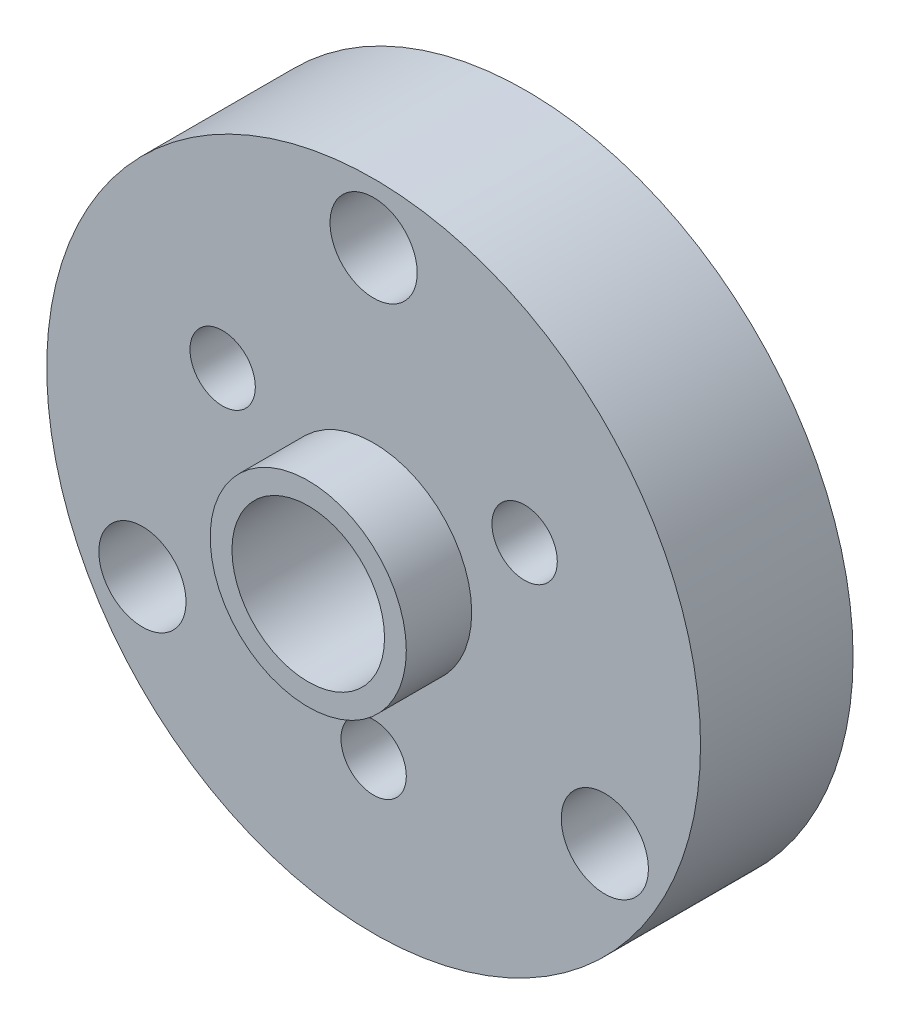
from build123d import *

# Parameters (mm, degrees)
ESQUISSE1_R      = 15
ESQUISSE1_R_2    = 3.5
ESQUISSE1_R_3    = 2
ESQUISSE1_R_4    = 1.5
EXTRUSION1_DEPTH = 7
ESQUISSE2_R      = 4.5
ESQUISSE2_R_2    = 3.5
EXTRUSION2_DEPTH = 3
ESQUISSE3_R      = 6
EXTRUSION3_DEPTH = 4
ESQUISSE4_R      = 5
ESQUISSE4_R_2    = 3.5
EXTRUSION4_DEPTH = 0.5


with BuildPart() as part:
    # Esquisse1 → Extrusion1 (new body)
    with BuildSketch(Plane.XY):
        Circle(ESQUISSE1_R)
        Circle(ESQUISSE1_R_2, mode=Mode.SUBTRACT)
        with Locations((10.608811196, -6.125)):
            Circle(ESQUISSE1_R_3, mode=Mode.SUBTRACT)
        with Locations((0, 12.25)):
            Circle(ESQUISSE1_R_3, mode=Mode.SUBTRACT)
        with Locations((-10.608811196, -6.125)):
            Circle(ESQUISSE1_R_3, mode=Mode.SUBTRACT)
        with Locations((-6.92820323, 4)):
            Circle(ESQUISSE1_R_4, mode=Mode.SUBTRACT)
        with Locations((6.92820323, 4)):
            Circle(ESQUISSE1_R_4, mode=Mode.SUBTRACT)
        with Locations((0, -8)):
            Circle(ESQUISSE1_R_4, mode=Mode.SUBTRACT)
    extrude(amount=EXTRUSION1_DEPTH)

    # Esquisse2 → Extrusion2 (add)
    with BuildSketch(Plane.XY.offset(7)):
        Circle(ESQUISSE2_R)
        Circle(ESQUISSE2_R_2, mode=Mode.SUBTRACT)
    extrude(amount=EXTRUSION2_DEPTH)

    # Esquisse3 → Extrusion3 (cut)
    with BuildSketch(Plane(origin=(0, 0, 0), x_dir=(-1, 0, 0), z_dir=(0, 0, -1))):
        Circle(ESQUISSE3_R)
    extrude(amount=-EXTRUSION3_DEPTH, mode=Mode.SUBTRACT)

    # Esquisse4 → Extrusion4 (cut)
    with BuildSketch(Plane(origin=(0, 0, 4), x_dir=(-1, 0, 0), z_dir=(0, 0, -1))):
        Circle(ESQUISSE4_R)
        Circle(ESQUISSE4_R_2, mode=Mode.SUBTRACT)
    extrude(amount=-EXTRUSION4_DEPTH, mode=Mode.SUBTRACT)


solid = part.part
